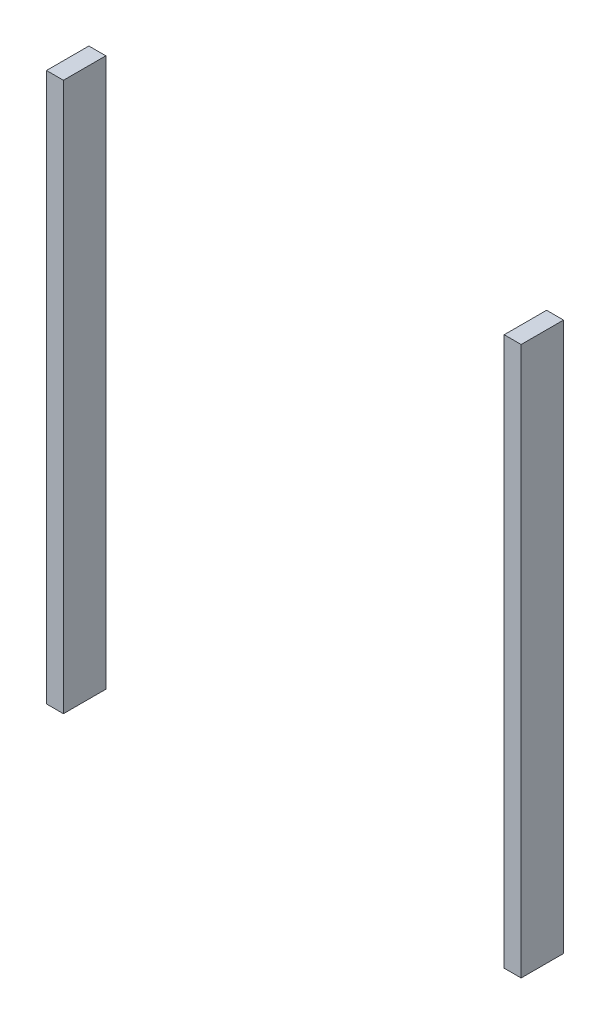
from build123d import *

# Parameters (mm, degrees)
SKETCH_2_W        = 5
SKETCH_2_H        = 161.81563722
EXTRUDE_2_DEPTH   = 6.25
EXTRUDE_2_2_DEPTH = 6.25


with BuildPart() as part:
    # 스케치2 → 보스-돌출2 (new body, symmetric)
    with BuildSketch(Plane.XY):
        with Locations((-67.5, 8.84115151)):
            Rectangle(SKETCH_2_W, SKETCH_2_H)
    extrude(amount=EXTRUDE_2_DEPTH, both=True)


with BuildPart() as body_2:
    # 스케치2 → Extrude 2 2 (new body, symmetric)
    with BuildSketch(Plane.XY):
        with Locations((67.5, 8.84115151)):
            Rectangle(SKETCH_2_W, SKETCH_2_H)
    extrude(amount=EXTRUDE_2_2_DEPTH, both=True)


solid = Compound([part.part, body_2.part])
